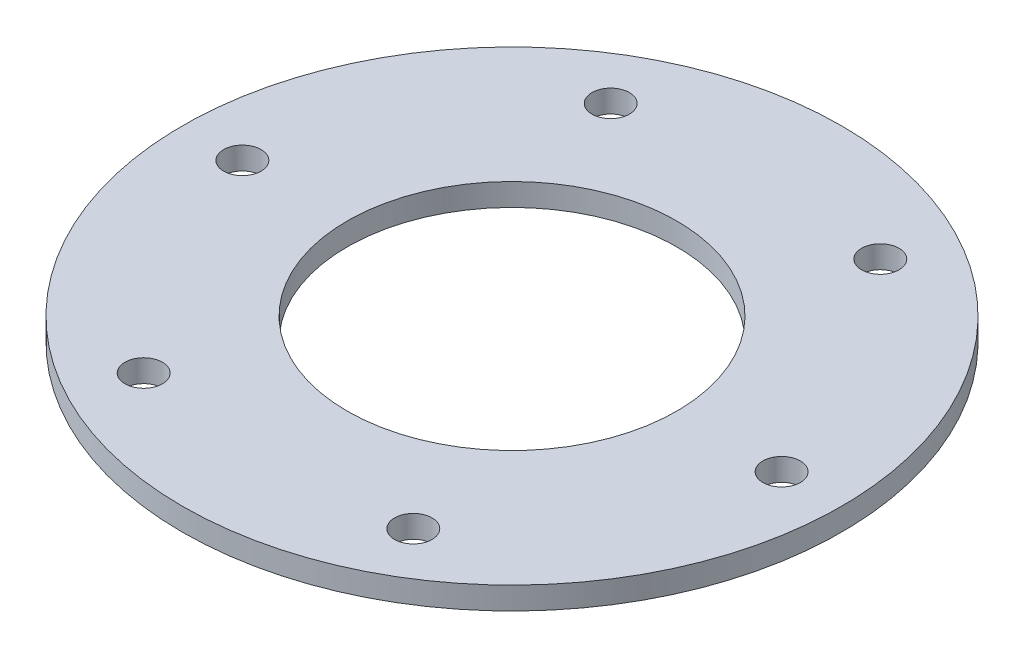
from build123d import *

# Parameters (mm, degrees)
SKETCH1_R           = 139.7
SKETCH1_R_2         = 69.85
BOSS_EXTRUDE1_DEPTH = 9.525
CUT_EXTRUDE1_REACH  = 11.525
SKETCH2_R           = 7.9375


with BuildPart() as part:
    # Sketch1 → Boss-Extrude1 (new body)
    with BuildSketch(Plane(origin=(0, 0, 0), x_dir=(1, 0, 0), z_dir=(0, 1, 0))):
        with Locations((-63.18889636, 128.089070316)):
            Circle(SKETCH1_R)
        with Locations((-63.18889636, 128.089070316)):
            Circle(SKETCH1_R_2, mode=Mode.SUBTRACT)
    extrude(amount=BOSS_EXTRUDE1_DEPTH)

    # Sketch2 → Cut-Extrude1 (cut, up to next)
    with BuildSketch(Plane(origin=(0, 9.525, 0), x_dir=(1, 0, 0), z_dir=(0, 1, 0)), mode=Mode.PRIVATE) as cut_extrude1_sk1:
        with Locations((51.11110364, 128.089070316)):
            Circle(SKETCH2_R)
    cut_extrude1_tool1 = extrude(cut_extrude1_sk1.sketch, amount=-CUT_EXTRUDE1_REACH, mode=Mode.PRIVATE) & part.part
    add(cut_extrude1_tool1.solids().sort_by_distance((51.111104, 9.525, -128.08907))[0], mode=Mode.SUBTRACT)
    # Sketch2 → Cut-Extrude1 (cut, up to next)
    with BuildSketch(Plane(origin=(0, 9.525, 0), x_dir=(1, 0, 0), z_dir=(0, 1, 0)), mode=Mode.PRIVATE) as cut_extrude1_sk2:
        with Locations((-6.03889636, 227.075773969)):
            Circle(SKETCH2_R)
    cut_extrude1_tool2 = extrude(cut_extrude1_sk2.sketch, amount=-CUT_EXTRUDE1_REACH, mode=Mode.PRIVATE) & part.part
    add(cut_extrude1_tool2.solids().sort_by_distance((-6.038896, 9.525, -227.075774))[0], mode=Mode.SUBTRACT)
    # Sketch2 → Cut-Extrude1 (cut, up to next)
    with BuildSketch(Plane(origin=(0, 9.525, 0), x_dir=(1, 0, 0), z_dir=(0, 1, 0)), mode=Mode.PRIVATE) as cut_extrude1_sk3:
        with Locations((-120.33889636, 227.075773969)):
            Circle(SKETCH2_R)
    cut_extrude1_tool3 = extrude(cut_extrude1_sk3.sketch, amount=-CUT_EXTRUDE1_REACH, mode=Mode.PRIVATE) & part.part
    add(cut_extrude1_tool3.solids().sort_by_distance((-120.338896, 9.525, -227.075774))[0], mode=Mode.SUBTRACT)
    # Sketch2 → Cut-Extrude1 (cut, up to next)
    with BuildSketch(Plane(origin=(0, 9.525, 0), x_dir=(1, 0, 0), z_dir=(0, 1, 0)), mode=Mode.PRIVATE) as cut_extrude1_sk4:
        with Locations((-177.48889636, 128.089070316)):
            Circle(SKETCH2_R)
    cut_extrude1_tool4 = extrude(cut_extrude1_sk4.sketch, amount=-CUT_EXTRUDE1_REACH, mode=Mode.PRIVATE) & part.part
    add(cut_extrude1_tool4.solids().sort_by_distance((-177.488896, 9.525, -128.08907))[0], mode=Mode.SUBTRACT)
    # Sketch2 → Cut-Extrude1 (cut, up to next)
    with BuildSketch(Plane(origin=(0, 9.525, 0), x_dir=(1, 0, 0), z_dir=(0, 1, 0)), mode=Mode.PRIVATE) as cut_extrude1_sk5:
        with Locations((-120.33889636, 29.102366663)):
            Circle(SKETCH2_R)
    cut_extrude1_tool5 = extrude(cut_extrude1_sk5.sketch, amount=-CUT_EXTRUDE1_REACH, mode=Mode.PRIVATE) & part.part
    add(cut_extrude1_tool5.solids().sort_by_distance((-120.338896, 9.525, -29.102367))[0], mode=Mode.SUBTRACT)
    # Sketch2 → Cut-Extrude1 (cut, up to next)
    with BuildSketch(Plane(origin=(0, 9.525, 0), x_dir=(1, 0, 0), z_dir=(0, 1, 0)), mode=Mode.PRIVATE) as cut_extrude1_sk6:
        with Locations((-6.03889636, 29.102366663)):
            Circle(SKETCH2_R)
    cut_extrude1_tool6 = extrude(cut_extrude1_sk6.sketch, amount=-CUT_EXTRUDE1_REACH, mode=Mode.PRIVATE) & part.part
    add(cut_extrude1_tool6.solids().sort_by_distance((-6.038896, 9.525, -29.102367))[0], mode=Mode.SUBTRACT)


solid = part.part
